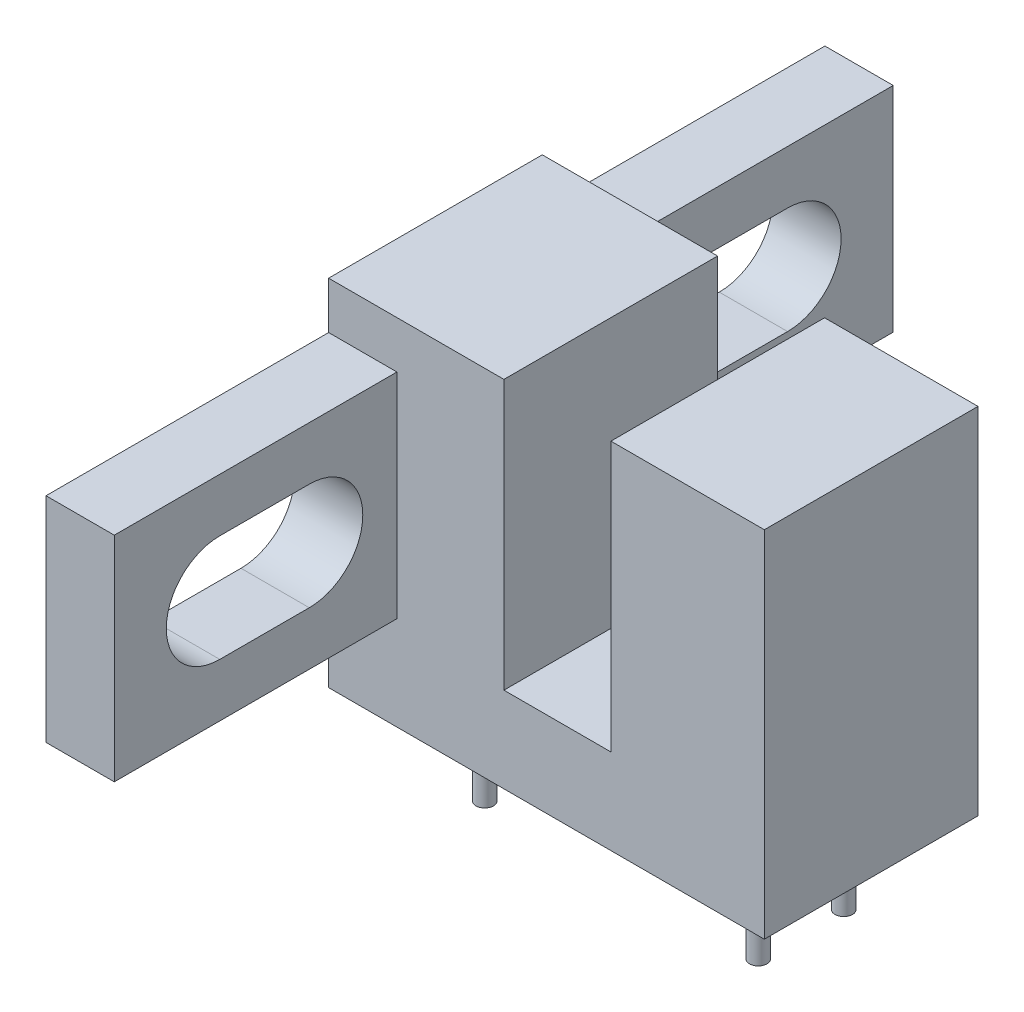
from build123d import *

# Parameters (mm, degrees)
SKETCH2_W           = 12.95
SKETCH2_H           = 6.35
BOSS_EXTRUDE1_DEPTH = 2.54
SKETCH3_W           = 5.21
SKETCH3_H           = 6.35
SKETCH3_W_2         = 4.56
BOSS_EXTRUDE2_DEPTH = 8
SKETCH5_R           = 0.26
BOSS_EXTRUDE5_DEPTH = 2.5
SKETCH6_W           = 8.4
SKETCH6_H           = 6.35
BOSS_EXTRUDE6_DEPTH = 2.03


with BuildPart() as part:
    # Sketch2 → Boss-Extrude1 (new body)
    with BuildSketch(Plane(origin=(0, 0, 0), x_dir=(1, 0, 0), z_dir=(0, 1, 0))):
        Rectangle(SKETCH2_W, SKETCH2_H)
    extrude(amount=BOSS_EXTRUDE1_DEPTH)

    # Sketch3 → Boss-Extrude2 (add)
    with BuildSketch(Plane(origin=(0, 2.54, 0), x_dir=(1, 0, 0), z_dir=(0, 1, 0))):
        with Locations((-3.87, 0)):
            Rectangle(SKETCH3_W, SKETCH3_H)
        with Locations((4.195, 0)):
            Rectangle(SKETCH3_W_2, SKETCH3_H)
    extrude(amount=BOSS_EXTRUDE2_DEPTH)

    # Sketch5 → Boss-Extrude5 (add)
    with BuildSketch(Plane.XZ):
        with Locations((-3.74, -1.27)):
            Circle(SKETCH5_R)
        with Locations((-3.74, 1.27)):
            Circle(SKETCH5_R)
        with Locations((4.39, -1.27)):
            Circle(SKETCH5_R)
        with Locations((4.39, 1.27)):
            Circle(SKETCH5_R)
    extrude(amount=BOSS_EXTRUDE5_DEPTH)

    # Sketch6 → Boss-Extrude6 (add)
    with BuildSketch(Plane.ZY.offset(6.475)):
        with Locations((-7.375, 5.965)):
            Rectangle(SKETCH6_W, SKETCH6_H)
        with BuildLine():
            ThreePointArc((-8.436140087, 4.375), (-10.026140087, 5.965), (-8.436140087, 7.555))
            Line((-8.436140087, 7.555), (-5.776140087, 7.555))
            ThreePointArc((-5.776140087, 7.555), (-4.651840305, 7.089299782), (-4.186140087, 5.965))
            ThreePointArc((-4.186140087, 5.965), (-4.651840305, 4.840700218), (-5.776140087, 4.375))
            Line((-5.776140087, 4.375), (-8.436140087, 4.375))
        make_face(mode=Mode.SUBTRACT)
        with Locations((7.375, 5.965)):
            Rectangle(SKETCH6_W, SKETCH6_H)
        with BuildLine():
            ThreePointArc((5.78, 4.375), (4.19, 5.965), (5.78, 7.555))
            Line((5.78, 7.555), (8.44, 7.555))
            ThreePointArc((8.44, 7.555), (9.564299782, 7.089299782), (10.03, 5.965))
            ThreePointArc((10.03, 5.965), (9.564299782, 4.840700218), (8.44, 4.375))
            Line((8.44, 4.375), (5.78, 4.375))
        make_face(mode=Mode.SUBTRACT)
    extrude(amount=-BOSS_EXTRUDE6_DEPTH)


solid = part.part
